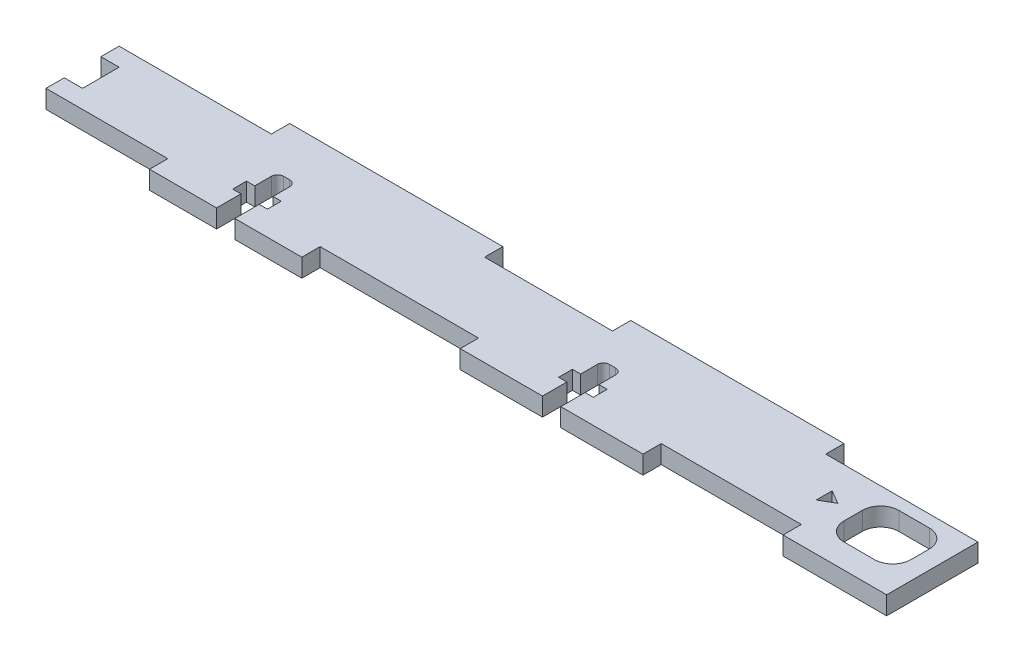
from build123d import *

# Parameters (mm, degrees)
SKETCH1_W                = 141
SKETCH1_H                = 12
BOSS_EXTRUDE1_DEPTH      = 1.5
SKETCH2_W                = 30
SKETCH2_H                = 3
SKETCH2_W_2              = 17
BOSS_EXTRUDE2_DEPTH      = 1.5
SKETCH12_W               = 25
SKETCH12_H               = 3
BOSS_EXTRUDE3_DEPTH      = 1.5
CUT_EXTRUDE8_DEPTH       = 2.5
CUT_EXTRUDE8_DEPTH_BACK  = 2.5
SKETCH13_W               = 35
SKETCH13_H               = 3
BOSS_EXTRUDE4_DEPTH      = 1.5
SKETCH15_W               = 11
SKETCH15_H               = 9
CUT_EXTRUDE10_DEPTH      = 2.5
CUT_EXTRUDE10_DEPTH_BACK = 2.5
FILLET4_R                = 3
CUT_EXTRUDE11_DEPTH      = 2.5
CUT_EXTRUDE11_DEPTH_BACK = 2.5
SKETCH17_W               = 3
SKETCH17_H               = 6
CUT_EXTRUDE12_DEPTH      = 2.5
CUT_EXTRUDE12_DEPTH_BACK = 2.5


with BuildPart() as part:
    # Sketch1 → Boss-Extrude1 (new body, symmetric)
    with BuildSketch(Plane(origin=(0, 0, 0), x_dir=(1, 0, 0), z_dir=(0, 1, 0))):
        Rectangle(SKETCH1_W, SKETCH1_H)
    extrude(amount=BOSS_EXTRUDE1_DEPTH, both=True)

    # Sketch2 → Boss-Extrude2 (add, symmetric)
    with BuildSketch(Plane(origin=(0, 0, 0), x_dir=(1, 0, 0), z_dir=(0, 1, 0))):
        with Locations((15.5, -7.5)):
            Rectangle(SKETCH2_W, SKETCH2_H)
        with Locations((62, -7.5)):
            Rectangle(SKETCH2_W_2, SKETCH2_H)
    extrude(amount=BOSS_EXTRUDE2_DEPTH, both=True)

    # Sketch12 → Boss-Extrude3 (add, symmetric)
    with BuildSketch(Plane(origin=(0, 0, 0), x_dir=(1, 0, 0), z_dir=(0, 1, 0))):
        with Locations((-38, -7.5)):
            Rectangle(SKETCH12_W, SKETCH12_H)
    extrude(amount=BOSS_EXTRUDE3_DEPTH, both=True)

    # Sketch11 → Cut-Extrude8 (cut, two sides)
    with BuildSketch(Plane(origin=(0, 0, 0), x_dir=(1, 0, 0), z_dir=(0, 1, 0))) as cut_extrude8_sk:
        with BuildLine():
            Line((-39.5, -2.73), (-39.5, 0))
            ThreePointArc((-39.5, 0), (-39.207106781, 0.707106781), (-38.5, 1))
            Line((-38.5, 1), (-37.5, 1))
            ThreePointArc((-37.5, 1), (-36.792893219, 0.707106781), (-36.5, 0))
            Line((-36.5, 0), (-36.5, -2.73))
            Line((-36.5, -2.73), (-35.15, -2.73))
            Line((-35.15, -2.73), (-35.15, -5))
            Line((-35.15, -5), (-36.5, -5))
            Line((-36.5, -5), (-36.5, -9))
            Line((-36.5, -9), (-39.5, -9))
            Line((-39.5, -9), (-39.5, -5))
            Line((-39.5, -5), (-40.85, -5))
            Line((-40.85, -5), (-40.85, -2.73))
            Line((-40.85, -2.73), (-39.5, -2.73))
        make_face()
        with BuildLine():
            Line((14, -9), (17, -9))
            Line((17, -9), (17, -5))
            Line((17, -5), (18.35, -5))
            Line((18.35, -5), (18.35, -2.73))
            Line((18.35, -2.73), (17, -2.73))
            Line((17, -2.73), (17, 0))
            ThreePointArc((17, 0), (16.707106781, 0.707106781), (16, 1))
            Line((16, 1), (15, 1))
            ThreePointArc((15, 1), (14.292893219, 0.707106781), (14, 0))
            Line((14, 0), (14, -2.73))
            Line((14, -2.73), (12.65, -2.73))
            Line((12.65, -2.73), (12.65, -5))
            Line((12.65, -5), (14, -5))
            Line((14, -5), (14, -9))
        make_face()
    extrude(amount=CUT_EXTRUDE8_DEPTH, mode=Mode.SUBTRACT)
    extrude(cut_extrude8_sk.sketch, amount=-CUT_EXTRUDE8_DEPTH_BACK, mode=Mode.SUBTRACT)

    # Sketch13 → Boss-Extrude4 (add, symmetric)
    with BuildSketch(Plane(origin=(0, 0, 0), x_dir=(1, 0, 0), z_dir=(0, 1, 0))):
        with Locations((-28, 7.5)):
            Rectangle(SKETCH13_W, SKETCH13_H)
        with Locations((28, 7.5)):
            Rectangle(SKETCH13_W, SKETCH13_H)
    extrude(amount=BOSS_EXTRUDE4_DEPTH, both=True)

    # Sketch15 → Cut-Extrude10 (cut, two sides)
    with BuildSketch(Plane(origin=(0, 0, 0), x_dir=(1, 0, 0), z_dir=(0, 1, 0))) as cut_extrude10_sk:
        with Locations((62, -0.5)):
            Rectangle(SKETCH15_W, SKETCH15_H)
    extrude(amount=CUT_EXTRUDE10_DEPTH, mode=Mode.SUBTRACT)
    extrude(cut_extrude10_sk.sketch, amount=-CUT_EXTRUDE10_DEPTH_BACK, mode=Mode.SUBTRACT)

    # Fillet4
    fillet4_edges = [part.edges().sort_by_distance(p)[0] for p in [
        (56.5, 0, 5),
        (56.5, 0, -4),
        (67.5, 0, -4),
        (67.5, 0, 5),
    ]]
    fillet(fillet4_edges, radius=FILLET4_R)

    # Sketch16 → Cut-Extrude11 (cut, two sides)
    with BuildSketch(Plane(origin=(0, 0, 0), x_dir=(1, 0, 0), z_dir=(0, 1, 0))) as cut_extrude11_sk:
        Polygon((53.5, 0), (51.25, 1.299038106), (51.25, -1.299038106), align=None)
    extrude(amount=CUT_EXTRUDE11_DEPTH, mode=Mode.SUBTRACT)
    extrude(cut_extrude11_sk.sketch, amount=-CUT_EXTRUDE11_DEPTH_BACK, mode=Mode.SUBTRACT)

    # Sketch17 → Cut-Extrude12 (cut, two sides)
    with BuildSketch(Plane(origin=(0, 0, 0), x_dir=(1, 0, 0), z_dir=(0, 1, 0))) as cut_extrude12_sk:
        with Locations((-69, 0)):
            Rectangle(SKETCH17_W, SKETCH17_H)
    extrude(amount=CUT_EXTRUDE12_DEPTH, mode=Mode.SUBTRACT)
    extrude(cut_extrude12_sk.sketch, amount=-CUT_EXTRUDE12_DEPTH_BACK, mode=Mode.SUBTRACT)


solid = part.part
